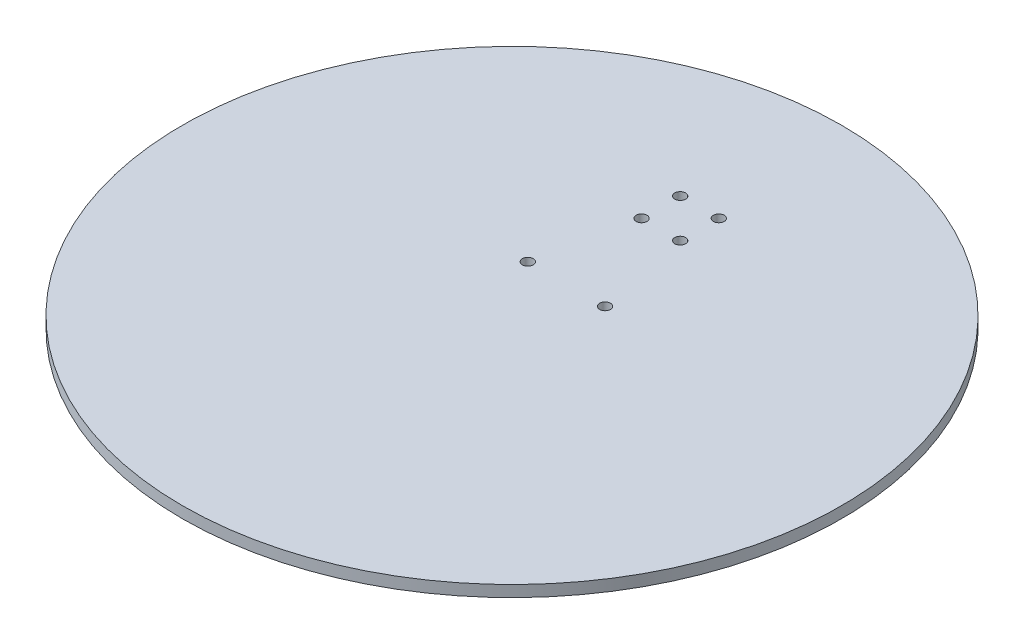
from build123d import *

# Parameters (mm, degrees)
SKETCH1_R           = 136.5
SKETCH1_R_2         = 2.25
BOSS_EXTRUDE1_DEPTH = 4.7


with BuildPart() as part:
    # Sketch1 → Boss-Extrude1 (new body)
    with BuildSketch(Plane(origin=(0, 0, 0), x_dir=(1, 0, 0), z_dir=(0, 1, 0))):
        Circle(SKETCH1_R)
        with Locations((-8, 77.66)):
            Circle(SKETCH1_R_2, mode=Mode.SUBTRACT)
        with Locations((8, 77.66)):
            Circle(SKETCH1_R_2, mode=Mode.SUBTRACT)
        with Locations((8, 61.66)):
            Circle(SKETCH1_R_2, mode=Mode.SUBTRACT)
        with Locations((-8, 61.66)):
            Circle(SKETCH1_R_2, mode=Mode.SUBTRACT)
        with Locations((-16, 22.54)):
            Circle(SKETCH1_R_2, mode=Mode.SUBTRACT)
        with Locations((16, 22.54)):
            Circle(SKETCH1_R_2, mode=Mode.SUBTRACT)
    extrude(amount=BOSS_EXTRUDE1_DEPTH)


solid = part.part
